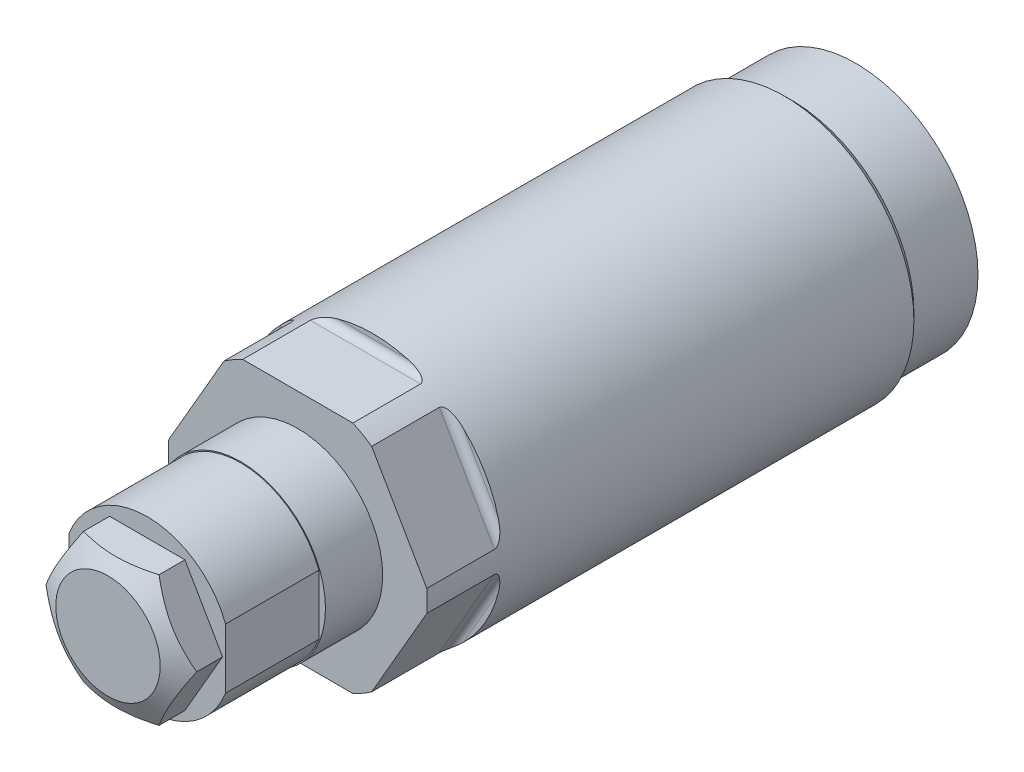
from build123d import *

# Parameters (mm, degrees)
SKETCH1_R           = 15.748
EXTRUDE1_DEPTH      = 67.8688
CUT_EXTRUDE1_DEPTH  = 18.8976
SKETCH11_W          = 18.3134
SKETCH11_H          = 10.3251
S2D0011_W           = 4.5466
S2D0011_H           = 6.35
CUT_EXTRUDE10_DEPTH = 11.3538
EXTRUDE2_DEPTH      = 4.7752
CIRPATTERN2_COUNT   = 6
SKETCH18_W          = 11.3538
SKETCH18_H          = 0.127


with BuildPart() as part:
    # Sketch1 → Extrude1 (new body)
    with BuildSketch(Plane.XY):
        Circle(SKETCH1_R)
    extrude(amount=EXTRUDE1_DEPTH)

    # Sketch2 → Cut-Extrude1 (cut, symmetric)
    with BuildSketch(Plane(origin=(0, 0, 0), x_dir=(0, 0, 1), z_dir=(1, 0, 0))):
        with BuildLine():
            Line((58.7248, 15.748), (58.7248, 15.1638))
            ThreePointArc((58.7248, 15.1638), (58.992621559, 14.517221559), (59.6392, 14.2494))
            Line((59.6392, 14.2494), (67.8688, 14.2494))
            Line((67.8688, 14.2494), (67.8688, 15.748))
            Line((67.8688, 15.748), (58.7248, 15.748))
        make_face()
    cut_extrude1 = extrude(amount=CUT_EXTRUDE1_DEPTH, both=True, mode=Mode.SUBTRACT)

    # Sketch10 → Cut-Revolve1 (revolve, cut)
    with BuildSketch(Plane(origin=(0, 0, 0), x_dir=(0, 0, 1), z_dir=(1, 0, 0)), mode=Mode.PRIVATE) as cut_revolve1_sk:
        Polygon((0, 14.8717), (7.7978, 14.8717), (8.6741, 15.748), (0, 15.748), align=None)
    revolve(cut_revolve1_sk.sketch.rotate(Axis((0, 0, -0.433705), (0, 0, 1)), 90), axis=Axis((0, 0, -0.433705), (0, 0, 1)), mode=Mode.SUBTRACT)  # turned: the seam where the file's is

    # Sketch11 → Revolve1 (revolve)
    with BuildSketch(Plane(origin=(0, 0, 0), x_dir=(0, 0, -1), z_dir=(1, 0, 0)), mode=Mode.PRIVATE) as revolve1_sk:
        with Locations((-77.0255, 5.16255)):
            Rectangle(SKETCH11_W, SKETCH11_H)
    revolve(revolve1_sk.sketch.rotate(Axis((0, 0, 71.06412), (0, 0, -1)), 90), axis=Axis((0, 0, 71.06412), (0, 0, -1)))  # turned: the seam where the file's is

    # S2D0011 → Cut-Revolve2 (revolve, cut)
    with BuildSketch(Plane(origin=(-4.5466, 0, 70.3072), x_dir=(-1, 0, 0), z_dir=(0, 1, 0)), mode=Mode.PRIVATE) as cut_revolve2_sk:
        with Locations((-2.2733, 12.7)):
            Rectangle(S2D0011_W, S2D0011_H)
    revolve(cut_revolve2_sk.sketch.rotate(Axis((0, 0, 48.067068782), (0, 0, 1)), 180), axis=Axis((0, 0, 48.067068782), (0, 0, 1)), mode=Mode.SUBTRACT)  # turned: the seam where the file's is

    # Sketch14 → Cut-Extrude10 (cut)
    with BuildSketch(Plane.YX.offset(-86.1822)):
        with BuildLine():
            Line((-3.98523086, 9.525), (3.98523086, 9.525))
            ThreePointArc((3.98523086, 9.525), (0, 10.3251), (-3.98523086, 9.525))
        make_face()
        with BuildLine():
            Line((-3.98523086, -9.525), (3.98523086, -9.525))
            ThreePointArc((3.98523086, -9.525), (0, -10.3251), (-3.98523086, -9.525))
        make_face()
    extrude(amount=CUT_EXTRUDE10_DEPTH, mode=Mode.SUBTRACT)

    # Sketch15 → Extrude2 (add)
    with BuildSketch(Plane.XY.offset(86.1822)):
        Polygon((-4.582717762, 7.9375), (4.582717762, 7.9375), (9.165435523, 0), (4.582717762, -7.9375), (-4.582717762, -7.9375), (-9.165435523, 0), align=None)
    extrude(amount=EXTRUDE2_DEPTH)

    # Sketch16 → Cut-Revolve3 (revolve, cut)
    with BuildSketch(Plane(origin=(0, 0, 0), x_dir=(1, 0, 0), z_dir=(0, 1, 0))):
        Polygon((6.35, -90.9574), (9.165435523, -89.331907543), (9.165435523, -90.9574), align=None)
    revolve(axis=Axis((0, 0, 75.163674623), (0, 0, -1)), mode=Mode.SUBTRACT)

    # CirPattern2: Cut-Extrude1 ×6 about axis
    cirpattern2_axis = Axis((0, 0, 0), (0, 0, 1))
    for i in range(1, CIRPATTERN2_COUNT):
        add(cut_extrude1.rotate(cirpattern2_axis, i * 360 / CIRPATTERN2_COUNT), mode=Mode.SUBTRACT)

    # Sketch18 → Cut-Revolve4 (revolve, cut)
    with BuildSketch(Plane(origin=(0, 0, 0), x_dir=(0, 0, -1), z_dir=(1, 0, 0)), mode=Mode.PRIVATE) as cut_revolve4_sk:
        with Locations((-80.5053, 10.2616)):
            Rectangle(SKETCH18_W, SKETCH18_H)
    revolve(cut_revolve4_sk.sketch.rotate(Axis((0, 0, 0), (0, 0, 1)), 270), axis=Axis((0, 0, 0), (0, 0, 1)), mode=Mode.SUBTRACT)  # turned: the seam where the file's is


solid = part.part
